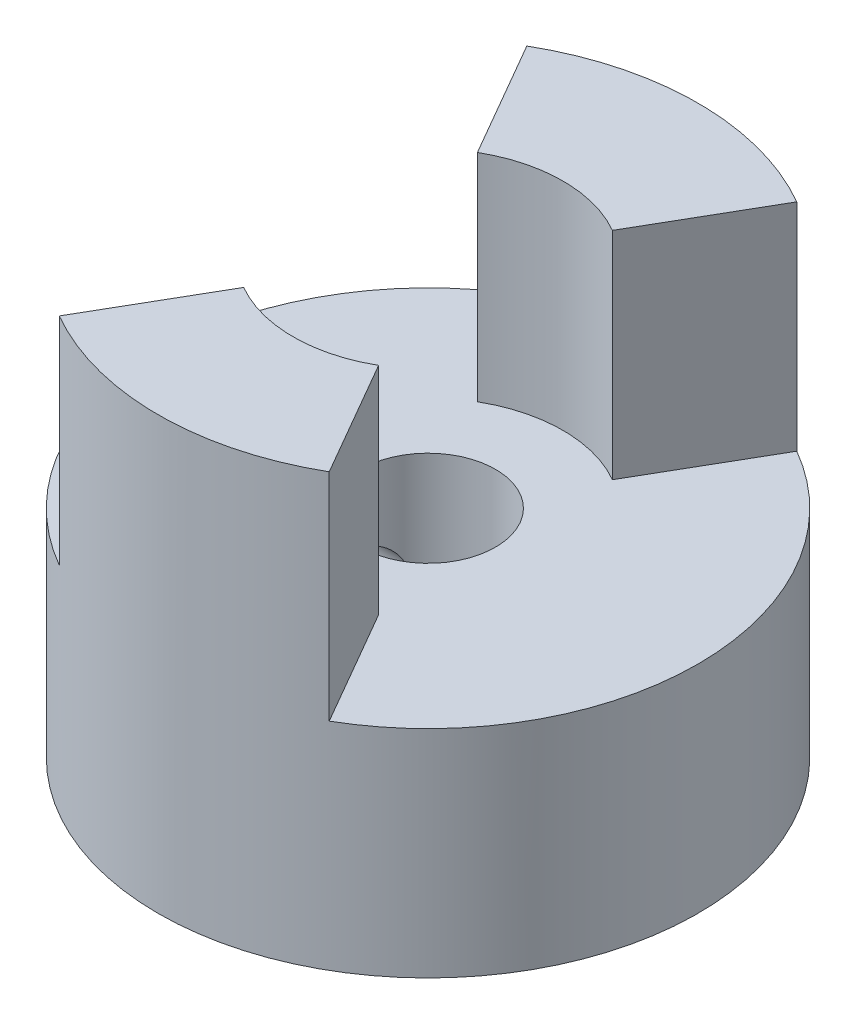
from build123d import *

# Parameters (mm, degrees)
SKETCH1_R                    = 6.35
BOSS_EXTRUDE1_DEPTH          = 10.16
F_1_8_0_125_DIAMETER_HOLE1_D = 3.175
SKETCH4_R                    = 3.175
CUT_EXTRUDE1_DEPTH           = 5.08
CUT_EXTRUDE2_DEPTH           = 5.08
F_2_56_TAPPED_HOLE1_REACH    = 18.12
F_2_56_TAPPED_HOLE1_BORE_R   = 0.889


with BuildPart() as part:
    # Sketch1 → Boss-Extrude1 (new body)
    with BuildSketch(Plane(origin=(0, 0, 0), x_dir=(1, 0, 0), z_dir=(0, 1, 0))):
        with Locations(Location((0, 0, 0), (0, 0, 270))):
            Circle(SKETCH1_R)
    extrude(amount=BOSS_EXTRUDE1_DEPTH)

    # 1/8 (0.125) Diameter Hole1 (through all)
    with Locations(Plane(origin=(0, 10.16, 0), x_dir=(1, 0, 0), z_dir=(0, 1, 0))):
        with Locations((0, 0)):
            Hole(F_1_8_0_125_DIAMETER_HOLE1_D / 2)

    # Sketch4 → Cut-Extrude1 (cut)
    with BuildSketch(Plane(origin=(0, 10.16, 0), x_dir=(1, 0, 0), z_dir=(0, 1, 0))):
        with Locations(Location((0, 0, 0), (0, 0, 270))):
            Circle(SKETCH4_R)
    extrude(amount=-CUT_EXTRUDE1_DEPTH, mode=Mode.SUBTRACT)

    # Sketch5 → Cut-Extrude2 (cut)
    with BuildSketch(Plane(origin=(0, 10.16, 0), x_dir=(1, 0, 0), z_dir=(0, 1, 0))):
        Polygon((0, 0), (-7.62, -13.198227154), (-7.62, 13.198227154), align=None)
    cut_extrude2 = extrude(amount=-CUT_EXTRUDE2_DEPTH, mode=Mode.SUBTRACT)

    # Mirror1: Cut-Extrude2 across plane
    add(cut_extrude2.mirror(Plane(origin=(0, 0, 0), x_dir=(0, 0, 1), z_dir=(1, 0, 0))), mode=Mode.SUBTRACT)

    # #2-56 Tapped Hole1 bore (on position points) → #2-56 Tapped Hole1 (cut, up to next)
    with BuildSketch(Plane(origin=(-6.349986105, 2.54, 0.013284072), x_dir=(-0.002091979827, 0, -0.999997811808), z_dir=(-0.999997811808, 0, 0.002091979827)), mode=Mode.PRIVATE) as f_2_56_tapped_hole1_sk1:
        Circle(F_2_56_TAPPED_HOLE1_BORE_R)
    f_2_56_tapped_hole1_tool1 = extrude(f_2_56_tapped_hole1_sk1.sketch, amount=-F_2_56_TAPPED_HOLE1_REACH, mode=Mode.PRIVATE) & part.part
    add(f_2_56_tapped_hole1_tool1.solids().sort_by_distance((-6.349986, 2.54, 0.013284))[0], mode=Mode.SUBTRACT)


solid = part.part
